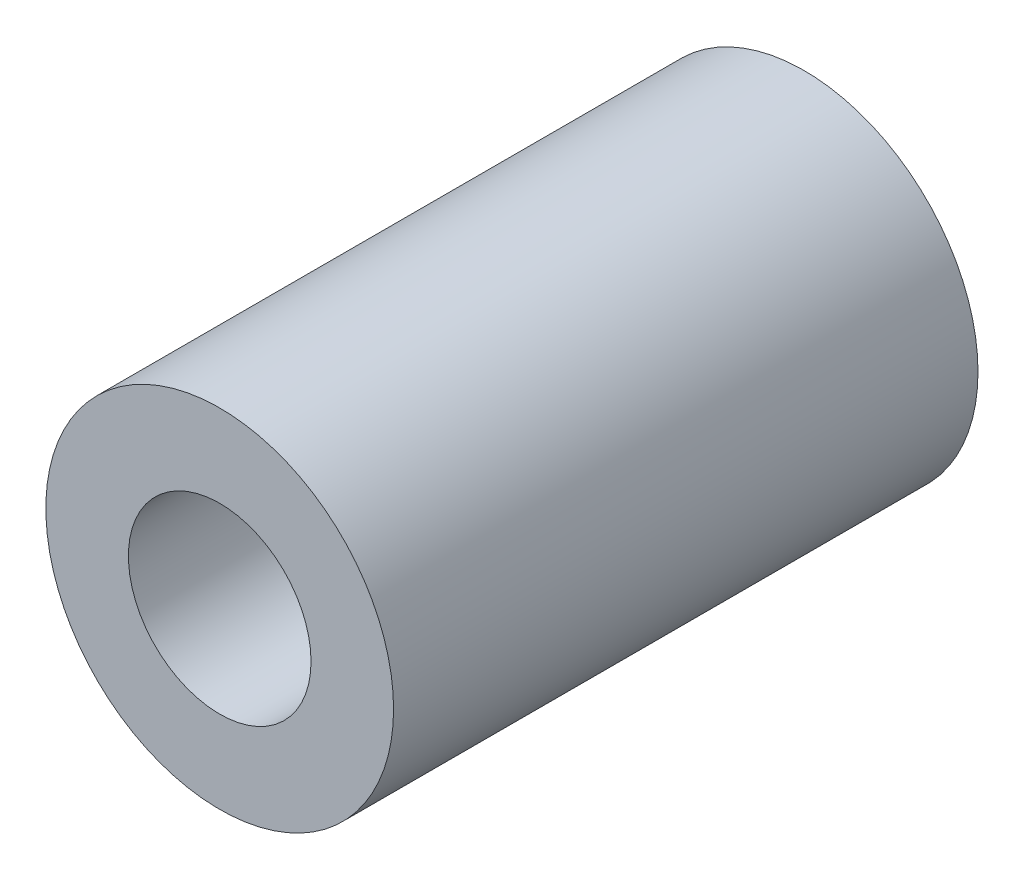
from build123d import *

# Parameters (mm, degrees)
SKETCH1_R           = 2.38
SKETCH1_R_2         = 1.25
BOSS_EXTRUDE1_DEPTH = 8


with BuildPart() as part:
    # Sketch1 → Boss-Extrude1 (new body)
    with BuildSketch(Plane.XY):
        Circle(SKETCH1_R)
        Circle(SKETCH1_R_2, mode=Mode.SUBTRACT)
    extrude(amount=BOSS_EXTRUDE1_DEPTH)


solid = part.part
